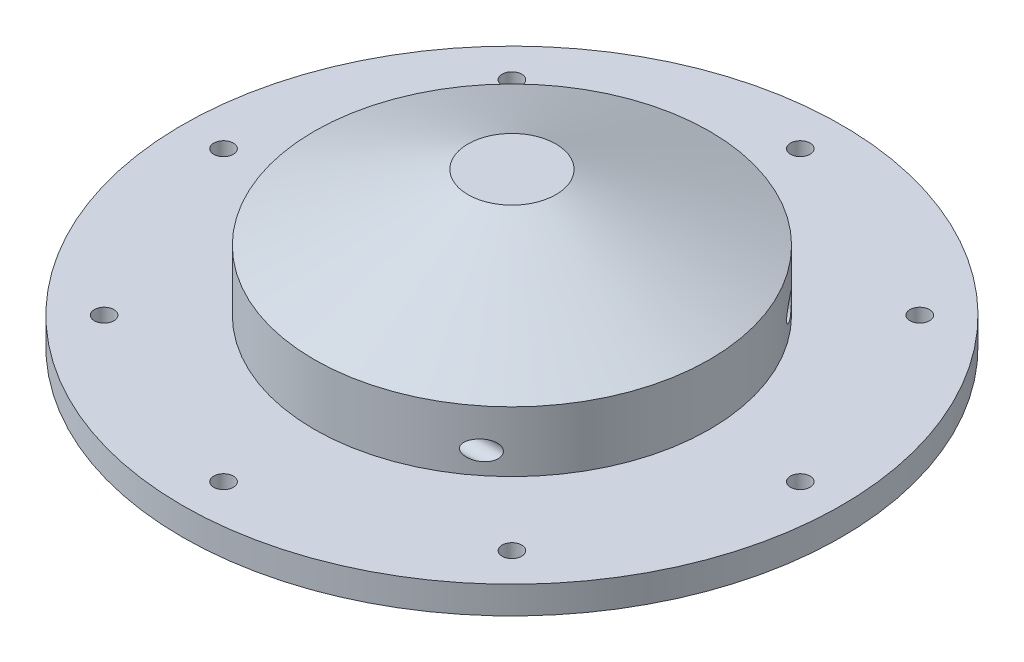
from build123d import *

# Parameters (mm, degrees)
SKETCH2_R                 = 38.1
BOSS_EXTRUDE1_DEPTH       = 3.175
TAP_DRILL_FOR_4_40_TAP1_D = 2.2606
CIRPATTERN1_COUNT         = 8
SKETCH7_R                 = 22.86
BOSS_EXTRUDE2_DEPTH       = 6.985
SKETCH8_R                 = 19.05
CUT_EXTRUDE1_DEPTH        = 8.255
SKETCH12_W                = 1.1303
SKETCH12_H                = 38.1
CIRPATTERN2_COUNT         = 4
SKETCH14_R                = 5.08
SKETCH13_R                = 22.86


with BuildPart() as part:
    # Sketch2 → Boss-Extrude1 (new body)
    with BuildSketch(Plane(origin=(0, 0, 0), x_dir=(1, 0, 0), z_dir=(0, 1, 0))):
        Circle(SKETCH2_R)
    extrude(amount=BOSS_EXTRUDE1_DEPTH)

    # Tap Drill for #4-40 Tap1 (through all)
    with Locations(Plane(origin=(0, 0, 0), x_dir=(-1, 0, 0), z_dir=(0, -1, 0))):
        with Locations((0, -33.3375)):
            tap_drill_for_4_40_tap1 = Hole(TAP_DRILL_FOR_4_40_TAP1_D / 2)

    # CirPattern1: Tap Drill for #4-40 Tap1 ×8 about axis
    cirpattern1_axis = Axis((0, 0, 0), (0, 1, 0))
    for i in range(1, CIRPATTERN1_COUNT):
        add(tap_drill_for_4_40_tap1.rotate(cirpattern1_axis, i * 360 / CIRPATTERN1_COUNT), mode=Mode.SUBTRACT)

    # Sketch7 → Boss-Extrude2 (add)
    with BuildSketch(Plane(origin=(0, 3.175, 0), x_dir=(1, 0, 0), z_dir=(0, 1, 0))):
        Circle(SKETCH7_R)
    extrude(amount=BOSS_EXTRUDE2_DEPTH)

    # Sketch8 → Cut-Extrude1 (cut)
    with BuildSketch(Plane.XZ):
        Circle(SKETCH8_R)
    extrude(amount=-CUT_EXTRUDE1_DEPTH, mode=Mode.SUBTRACT)

    # Sketch12 → Tap Drill for #4-40 Tap2 (revolve, cut)
    with BuildSketch(Plane(origin=(-17.78, 5.715, 0), x_dir=(0, 1, 0), z_dir=(1, 0, 0))):
        with Locations((0.56515, 19.05)):
            Rectangle(SKETCH12_W, SKETCH12_H)
    tap_drill_for_4_40_tap2 = revolve(axis=Axis((-17.78, 5.715, -6.35), (0, 0, 1)), mode=Mode.SUBTRACT)

    # CirPattern2: Tap Drill for #4-40 Tap2 ×4 about axis
    cirpattern2_axis = Axis((0, 10.16, 0), (0, 1, 0))
    for i in range(1, CIRPATTERN2_COUNT):
        add(tap_drill_for_4_40_tap2.rotate(cirpattern2_axis, i * 360 / CIRPATTERN2_COUNT), mode=Mode.SUBTRACT)

    # Sketch14 → Loft2 section 0
    with BuildSketch(Plane(origin=(0, 17.78, 0), x_dir=(1, 0, 0), z_dir=(0, 1, 0))):
        Circle(SKETCH14_R)
    # Sketch13 → Loft2 section 1
    with BuildSketch(Plane(origin=(0, 10.16, 0), x_dir=(1, 0, 0), z_dir=(0, 1, 0))):
        Circle(SKETCH13_R)
    loft()


solid = part.part
